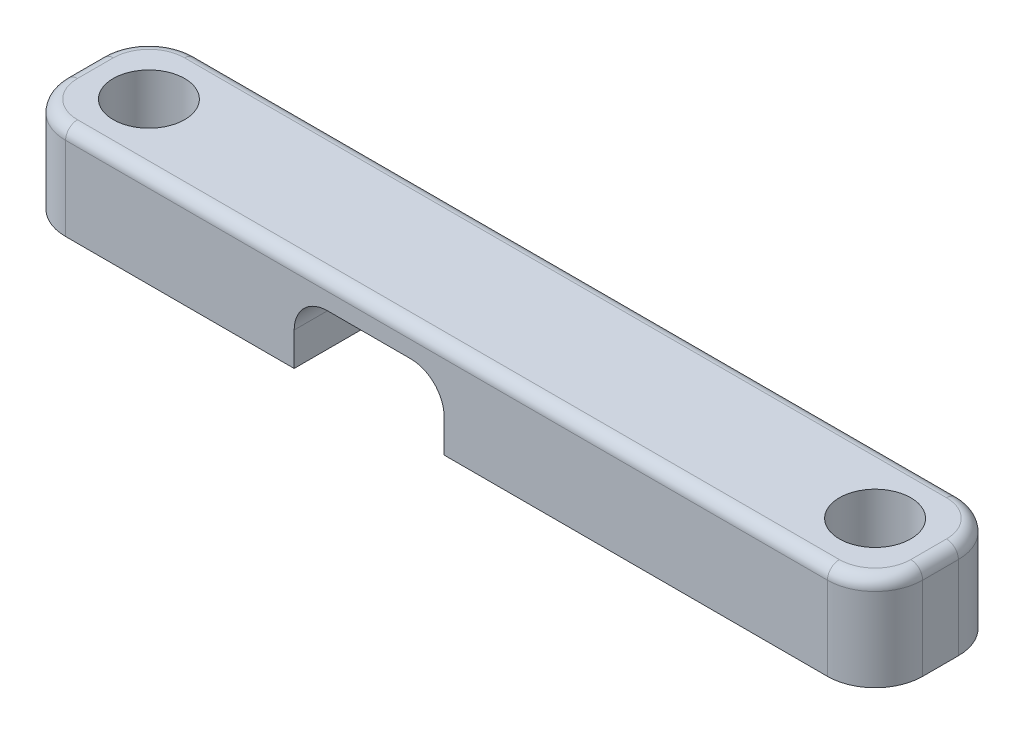
from build123d import *

# Parameters (mm, degrees)
SKETCH2_W           = 36
SKETCH2_H           = 5.5
SKETCH2_R           = 1.5
BOSS_EXTRUDE1_DEPTH = 4
SKETCH3_R           = 1.4
CUT_EXTRUDE1_DEPTH  = 5.5
FILLET1_R           = 2
FILLET2_R           = 0.5


with BuildPart() as part:
    # Sketch2 → Boss-Extrude1 (new body)
    with BuildSketch(Plane(origin=(0, 0, 0), x_dir=(1, 0, 0), z_dir=(0, 1, 0))):
        Rectangle(SKETCH2_W, SKETCH2_H)
        with Locations((-15.25, 0)):
            Circle(SKETCH2_R, mode=Mode.SUBTRACT)
        with Locations((15.25, 0)):
            Circle(SKETCH2_R, mode=Mode.SUBTRACT)
    extrude(amount=BOSS_EXTRUDE1_DEPTH)

    # Sketch3 → Cut-Extrude1 (cut)
    with BuildSketch(Plane.XY.offset(2.75)):
        with Locations((-5, 1.4)):
            Circle(SKETCH3_R)
        with BuildLine():
            ThreePointArc((-5.000000005, 0), (-5.989949495, 0.410050508), (-6.4, 1.4))
            Line((-6.4, 1.4), (-6.4, 0))
            Line((-6.4, 0), (-5.000000005, 0))
        make_face()
        with BuildLine():
            Line((-3.6, 0), (-3.6, 1.4))
            ThreePointArc((-3.6, 1.4), (-4.010050508, 0.410050505), (-5.000000005, 0))
            Line((-5.000000005, 0), (-3.6, 0))
        make_face()
        with BuildLine():
            Line((-1.5, 2.8), (-5, 2.8))
            ThreePointArc((-5, 2.8), (-4.010050506, 2.389949494), (-3.6, 1.4))
            Line((-3.6, 1.4), (-3.6, 0))
            Line((-3.6, 0), (-2.9, 0))
            Line((-2.9, 0), (-2.9, 1.4))
            ThreePointArc((-2.9, 1.4), (-2.489949494, 2.389949494), (-1.5, 2.8))
        make_face()
        with BuildLine():
            ThreePointArc((-1.500000004, 0), (-2.489949495, 0.410050508), (-2.9, 1.4))
            Line((-2.9, 1.4), (-2.9, 0))
            Line((-2.9, 0), (-1.500000004, 0))
        make_face()
        with Locations((-1.5, 1.4)):
            Circle(SKETCH3_R)
        with BuildLine():
            Line((-0.1, 0), (-0.1, 1.4))
            ThreePointArc((-0.1, 1.4), (-0.510050508, 0.410050505), (-1.500000004, 0))
            Line((-1.500000004, 0), (-0.1, 0))
        make_face()
    extrude(amount=-CUT_EXTRUDE1_DEPTH, mode=Mode.SUBTRACT)

    # Fillet1
    fillet1_edges = [part.edges().sort_by_distance(p)[0] for p in [
        (18, 2, 2.75),
        (-18, 2, 2.75),
        (-18, 2, -2.75),
        (18, 2, -2.75),
    ]]
    fillet(fillet1_edges, radius=FILLET1_R)

    # Fillet2
    fillet2_edges = [part.edges().sort_by_distance(p)[0] for p in [
        (0, 4, -2.75),
        (18, 4, 0),
        (-18, 4, 0),
        (0, 4, 2.75),
        (-17.414213562, 4, 2.164213562),
        (-17.414213562, 4, -2.164213562),
        (17.414213562, 4, 2.164213562),
        (17.414213562, 4, -2.164213562),
    ]]
    fillet(fillet2_edges, radius=FILLET2_R)


solid = part.part
